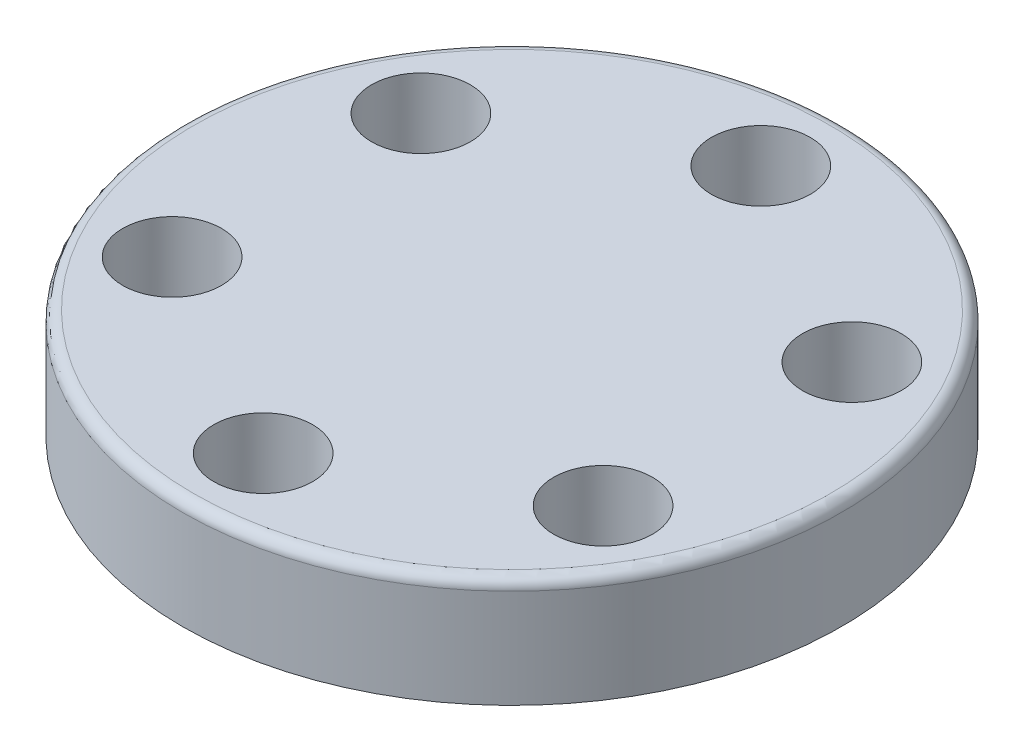
from build123d import *

# Parameters (mm, degrees)
SKETCH_1_R      = 30
SKETCH_1_R_2    = 4.5
EXTRUDE_2_DEPTH = 10
SKETCH_3_R      = 4.5
SKETCH_3_R_2    = 2.5
EXTRUDE_3_DEPTH = 3
FILLET_1_R      = 1


with BuildPart() as part:
    # ｽｹｯﾁ1 → ﾎﾞｽ - 押し出し2 (new body)
    with BuildSketch(Plane(origin=(0, 0, 0), x_dir=(1, 0, 0), z_dir=(0, 1, 0))):
        Circle(SKETCH_1_R)
        with Locations((0, -22.65)):
            Circle(SKETCH_1_R_2, mode=Mode.SUBTRACT)
        with Locations((-19.615475396, -11.325)):
            Circle(SKETCH_1_R_2, mode=Mode.SUBTRACT)
        with Locations((-19.615475396, 11.325)):
            Circle(SKETCH_1_R_2, mode=Mode.SUBTRACT)
        with Locations((0, 22.65)):
            Circle(SKETCH_1_R_2, mode=Mode.SUBTRACT)
        with Locations((19.615475396, 11.325)):
            Circle(SKETCH_1_R_2, mode=Mode.SUBTRACT)
        with Locations((19.615475396, -11.325)):
            Circle(SKETCH_1_R_2, mode=Mode.SUBTRACT)
    extrude(amount=EXTRUDE_2_DEPTH)

    # ｽｹｯﾁ3 → ﾎﾞｽ - 押し出し3 (add)
    with BuildSketch(Plane.XZ):
        with Locations((-19.615475396, -11.325)):
            Circle(SKETCH_3_R)
        with Locations((-19.615475396, -11.325)):
            Circle(SKETCH_3_R_2, mode=Mode.SUBTRACT)
        with Locations((-19.615475396, 11.325)):
            Circle(SKETCH_3_R)
        with Locations((-19.615475396, 11.325)):
            Circle(SKETCH_3_R_2, mode=Mode.SUBTRACT)
        with Locations((0, 22.65)):
            Circle(SKETCH_3_R)
        with Locations((0, 22.65)):
            Circle(SKETCH_3_R_2, mode=Mode.SUBTRACT)
        with Locations((19.615475396, 11.325)):
            Circle(SKETCH_3_R)
        with Locations((19.615475396, 11.325)):
            Circle(SKETCH_3_R_2, mode=Mode.SUBTRACT)
        with Locations((19.615475396, -11.325)):
            Circle(SKETCH_3_R)
        with Locations((19.615475396, -11.325)):
            Circle(SKETCH_3_R_2, mode=Mode.SUBTRACT)
        with Locations((0, -22.65)):
            Circle(SKETCH_3_R)
        with Locations((0, -22.65)):
            Circle(SKETCH_3_R_2, mode=Mode.SUBTRACT)
    extrude(amount=-EXTRUDE_3_DEPTH)

    # ﾌｨﾚｯﾄ1
    fillet_1_edges = [part.edges().sort_by_distance(p)[0] for p in [
        (-30, 10, 0),
    ]]
    fillet(fillet_1_edges, radius=FILLET_1_R)


solid = part.part
